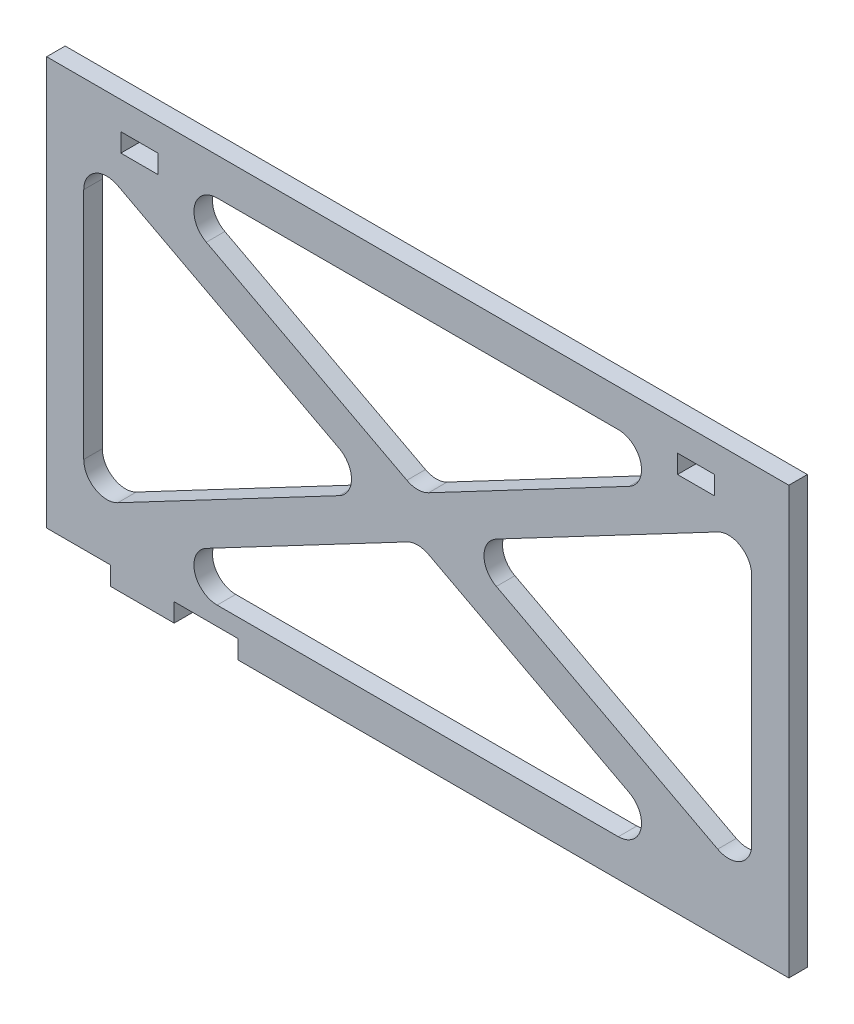
from build123d import *

# Parameters (mm, degrees)
SKETCH1_W               = 203.2
SKETCH1_H               = 116.84
BOSS_EXTRUDE1_DEPTH     = 5.08
FILLET1_R               = 6.35
SKETCH2_W               = 10.16
SKETCH2_H               = 5.08
CUT_EXTRUDE1_DEPTH      = 1
CUT_EXTRUDE1_DEPTH_BACK = 6.08
SKETCH3_W               = 17.4625
SKETCH3_H               = 5.08
CUT_EXTRUDE2_DEPTH      = 10.16


with BuildPart() as part:
    # Sketch1 → Boss-Extrude1 (new body)
    with BuildSketch(Plane.XY):
        Rectangle(SKETCH1_W, SKETCH1_H)
        Polygon((80.556430234, 48.26), (0, 5.744106266), (-80.556430234, 48.26), align=None, mode=Mode.SUBTRACT)
        Polygon((-91.44, 42.515893734), (-10.883569766, 0), (-91.44, -42.515893734), align=None, mode=Mode.SUBTRACT)
        Polygon((-80.556430234, -48.26), (0, -5.744106266), (80.556430234, -48.26), align=None, mode=Mode.SUBTRACT)
        Polygon((91.44, -42.515893734), (10.883569766, 0), (91.44, 42.515893734), align=None, mode=Mode.SUBTRACT)
    extrude(amount=BOSS_EXTRUDE1_DEPTH)

    # Fillet1
    fillet1_edges = [part.edges().sort_by_distance(p)[0] for p in [
        (-91.44, 42.515893734, 2.54),
        (-91.44, -42.515893734, 2.54),
        (-10.883569766, 0, 2.54),
        (-80.556430234, -48.26, 2.54),
        (80.556430234, -48.26, 2.54),
        (0, -5.744106266, 2.54),
        (80.556430234, 48.26, 2.54),
        (-80.556430234, 48.26, 2.54),
        (0, 5.744106266, 2.54),
        (91.44, -42.515893734, 2.54),
        (91.44, 42.515893734, 2.54),
        (10.883569766, 0, 2.54),
    ]]
    fillet(fillet1_edges, radius=FILLET1_R)

    # Sketch2 → Cut-Extrude1 (cut, two sides)
    with BuildSketch(Plane.XY.offset(5.08)) as cut_extrude1_sk:
        with Locations((-76.2, 48.26)):
            Rectangle(SKETCH2_W, SKETCH2_H)
        with Locations((76.2, 48.26)):
            Rectangle(SKETCH2_W, SKETCH2_H)
    extrude(amount=CUT_EXTRUDE1_DEPTH, mode=Mode.SUBTRACT)
    extrude(cut_extrude1_sk.sketch, amount=-CUT_EXTRUDE1_DEPTH_BACK, mode=Mode.SUBTRACT)

    # Sketch3 → Cut-Extrude2 (cut)
    with BuildSketch(Plane.XY.offset(5.08)):
        with Locations((-92.86875, -55.88)):
            Rectangle(SKETCH3_W, SKETCH3_H)
        with Locations((-57.94375, -55.88)):
            Rectangle(SKETCH3_W, SKETCH3_H)
    extrude(amount=-CUT_EXTRUDE2_DEPTH, mode=Mode.SUBTRACT)


solid = part.part
